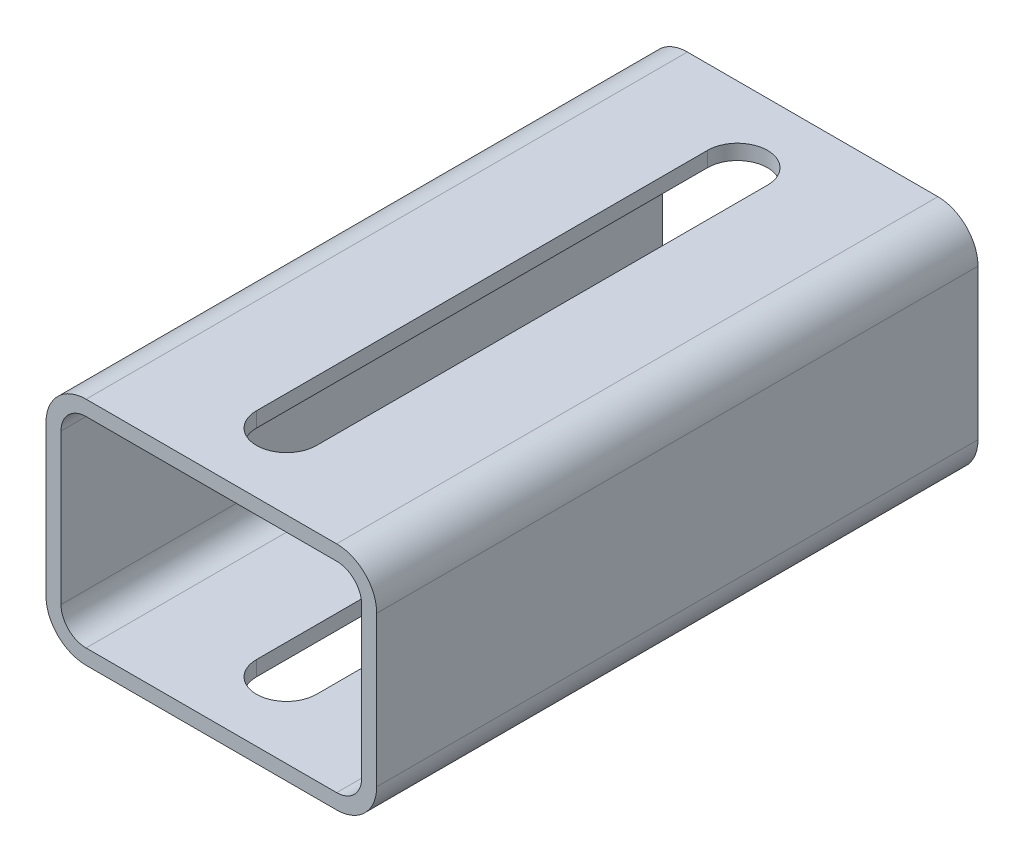
from build123d import *

# Parameters (mm, degrees)
EXTRUDE_THIN1_DEPTH = 60
CUT_EXTRUDE1_DEPTH  = 47


with BuildPart() as part:
    # Sketch2 → Extrude-Thin1 (new body, symmetric)
    with BuildSketch(Plane.XY):
        with BuildLine():
            Line((-25, 23), (25, 23))
            ThreePointArc((25, 23), (30.656854249, 20.656854249), (33, 15))
            Line((33, 15), (33, -15))
            ThreePointArc((33, -15), (30.656854249, -20.656854249), (25, -23))
            Line((25, -23), (-25, -23))
            ThreePointArc((-25, -23), (-30.656854249, -20.656854249), (-33, -15))
            Line((-33, -15), (-33, 15))
            ThreePointArc((-33, 15), (-30.656854249, 20.656854249), (-25, 23))
        make_face()
        with BuildLine():
            Line((-25, 20), (25, 20))
            ThreePointArc((25, 20), (28.535533906, 18.535533906), (30, 15))
            Line((30, 15), (30, -15))
            ThreePointArc((30, -15), (28.535533906, -18.535533906), (25, -20))
            Line((25, -20), (-25, -20))
            ThreePointArc((-25, -20), (-28.535533906, -18.535533906), (-30, -15))
            Line((-30, -15), (-30, 15))
            ThreePointArc((-30, 15), (-28.535533906, 18.535533906), (-25, 20))
        make_face(mode=Mode.SUBTRACT)
    extrude(amount=EXTRUDE_THIN1_DEPTH, both=True)

    # Sketch3 → Cut-Extrude1 (cut, through all)
    with BuildSketch(Plane(origin=(0, 23, 0), x_dir=(1, 0, 0), z_dir=(0, 1, 0))):
        with BuildLine():
            Line((-6, -45), (-6, 45))
            ThreePointArc((-6, 45), (0, 51), (6, 45))
            Line((6, 45), (6, -45))
            ThreePointArc((6, -45), (0, -51), (-6, -45))
        make_face()
    extrude(amount=-CUT_EXTRUDE1_DEPTH, mode=Mode.SUBTRACT)


solid = part.part
